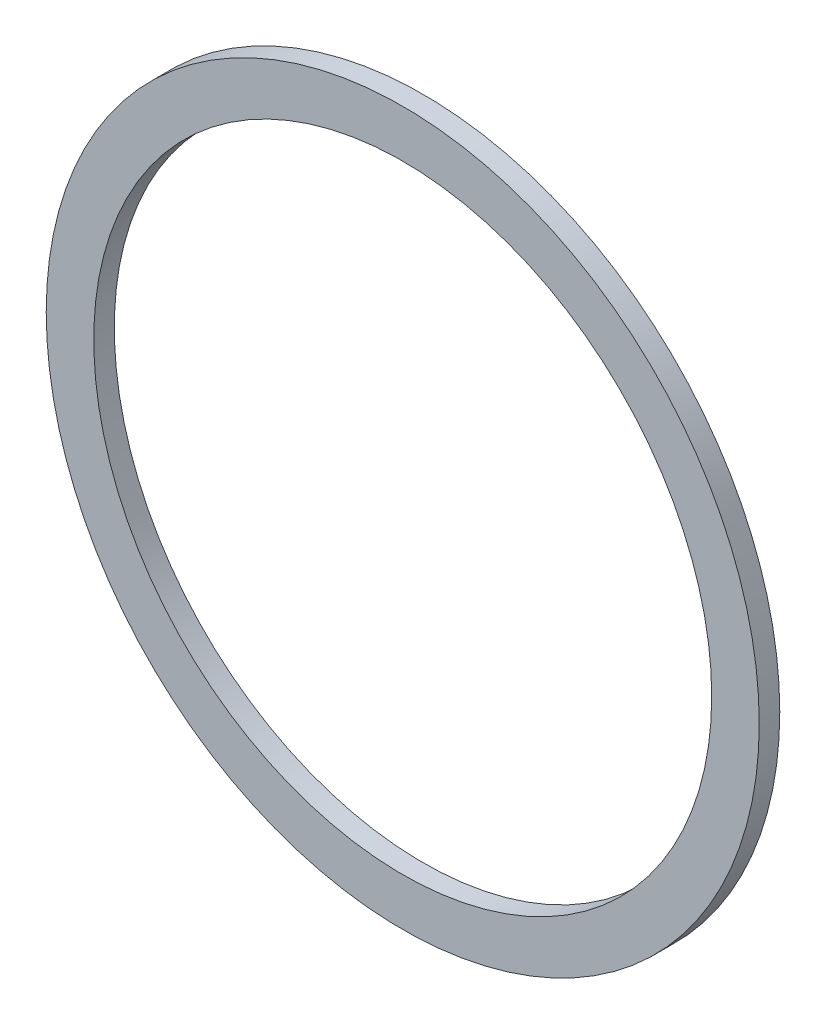
from build123d import *

# Parameters (mm, degrees)
SKETCH1_R           = 75
SKETCH1_R_2         = 65
BOSS_EXTRUDE1_DEPTH = 4.318


with BuildPart() as part:
    # Sketch1 → Boss-Extrude1 (new body)
    with BuildSketch(Plane.XY):
        Circle(SKETCH1_R)
        Circle(SKETCH1_R_2, mode=Mode.SUBTRACT)
    extrude(amount=BOSS_EXTRUDE1_DEPTH)


solid = part.part
